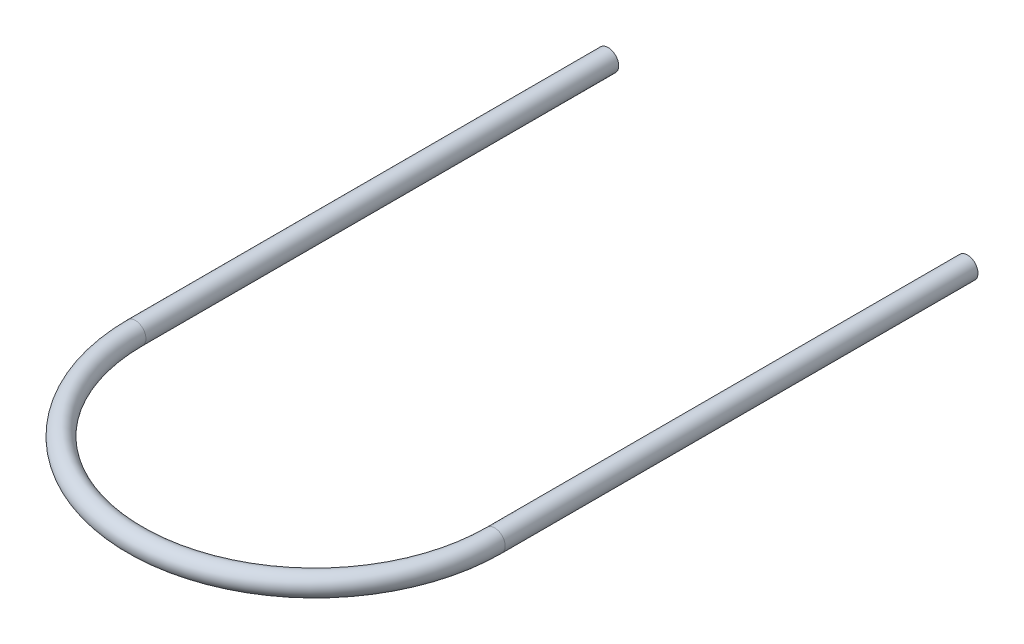
from build123d import *

# Parameters (mm, degrees)
SWEEP3_PROFILE_R = 14.224


with BuildPart() as part:
    # Sweep3: sweep along a path in Sketch2
    with BuildLine(Plane(origin=(0, 0, 0), x_dir=(1, 0, 0), z_dir=(0, 1, 0))) as sweep3_path:
        Line((-241.3, 635), (-241.3, 0))
        ThreePointArc((-241.3, 0), (0, -241.3), (241.3, 0))
        Line((241.3, 0), (241.3, 635))
    # Sweep3 profile (on start of the path) → Sweep3 (sweep)
    with BuildSketch(Plane(origin=(-241.3, 0, -635), x_dir=(1, 0, 0), z_dir=(0, 0, 1))):
        Circle(SWEEP3_PROFILE_R)
    sweep(path=sweep3_path.line)


solid = part.part
